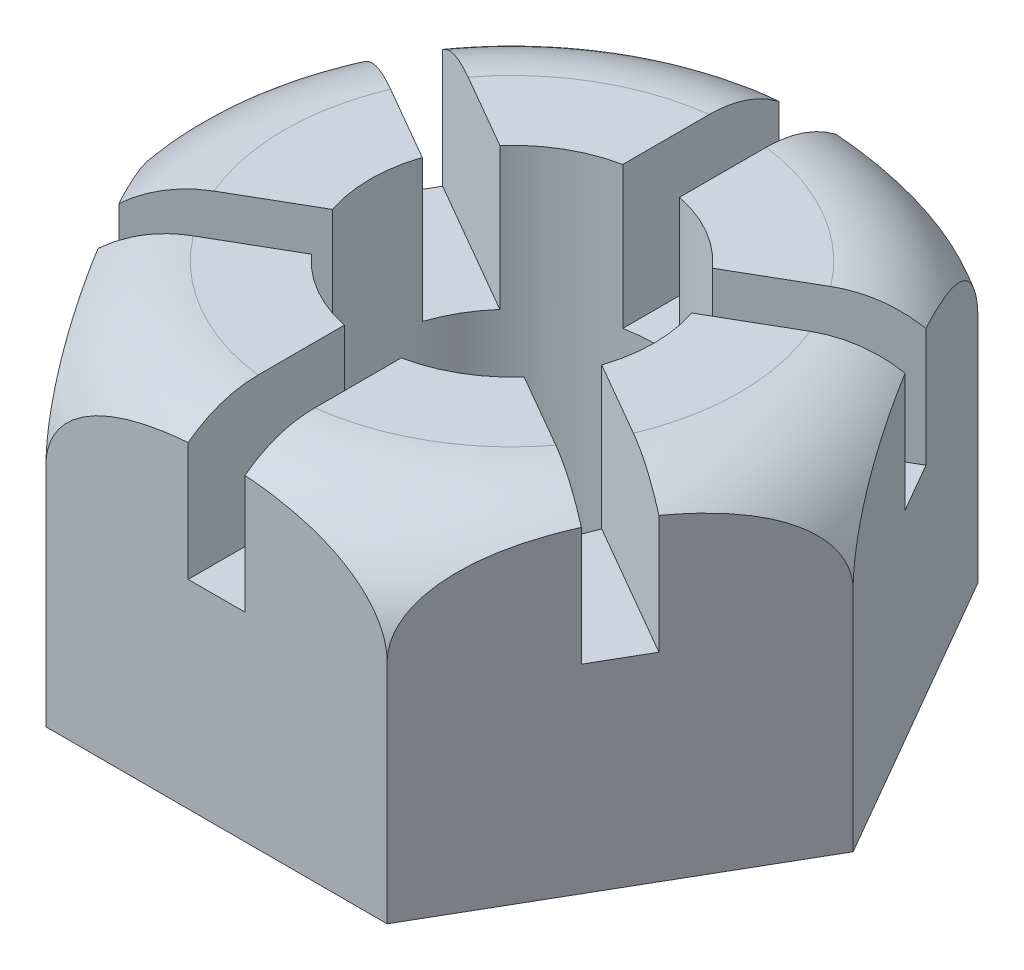
from build123d import *

# Parameters (mm, degrees)
BOSS_EXTRUDE1_DEPTH = 60
SKETCH2_R           = 25
CUT_EXTRUDE1_DEPTH  = 60
SKETCH3_W           = 10
SKETCH3_H           = 25
CUT_EXTRUDE2_DEPTH  = 40
CIRPATTERN1_COUNT   = 6


with BuildPart() as part:
    # Sketch1 → Boss-Extrude1 (new body)
    with BuildSketch(Plane(origin=(0, 0, 0), x_dir=(1, 0, 0), z_dir=(0, 1, 0))):
        Polygon((-60.044427996, 0), (-30.022213998, -52), (30.022213998, -52), (60.044427996, 0), (30.022213998, 52), (-30.022213998, 52), align=None)
    extrude(amount=BOSS_EXTRUDE1_DEPTH)

    # Sketch2 → Cut-Extrude1 (cut)
    with BuildSketch(Plane(origin=(0, 60, 0), x_dir=(1, 0, 0), z_dir=(0, 1, 0))):
        Circle(SKETCH2_R)
    extrude(amount=-CUT_EXTRUDE1_DEPTH, mode=Mode.SUBTRACT)

    # Sketch3 → Cut-Extrude2 (cut)
    with BuildSketch(Plane.XY.offset(52)):
        with Locations((0, 47.5)):
            Rectangle(SKETCH3_W, SKETCH3_H)
    cut_extrude2 = extrude(amount=-CUT_EXTRUDE2_DEPTH, mode=Mode.SUBTRACT)

    # CirPattern1: Cut-Extrude2 ×6 about axis
    cirpattern1_axis = Axis((0, 0, 0), (0, 1, 0))
    for i in range(1, CIRPATTERN1_COUNT):
        add(cut_extrude2.rotate(cirpattern1_axis, i * 360 / CIRPATTERN1_COUNT), mode=Mode.SUBTRACT)

    # Sketch4 → Cut-Revolve1 (revolve, cut)
    with BuildSketch(Plane.XY):
        with BuildLine():
            Line((40.044427996, 60), (60.044427996, 60))
            Line((60.044427996, 60), (60.044427996, 40))
            ThreePointArc((60.044427996, 40), (54.186563619, 54.142135624), (40.044427996, 60))
        make_face()
    revolve(axis=Axis((0, 0, 0), (0, 1, 0)), mode=Mode.SUBTRACT)


solid = part.part
